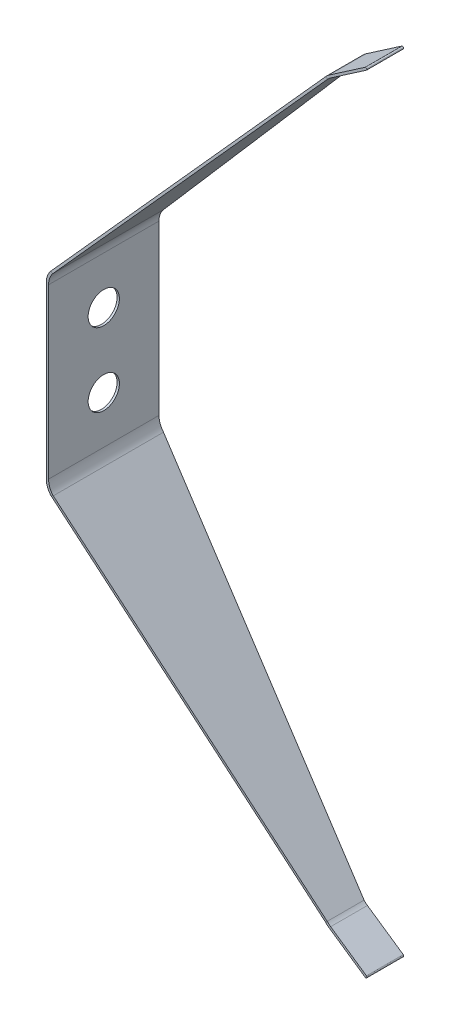
from build123d import *

# Parameters (mm, degrees)
ESTRUSIONE_ESTRUSIONE1_DEPTH      = 6
ESTRUSIONE_ESTRUSIONE1_DEPTH_BACK = 6
FORO_PER_VITE_M3_1_D              = 3.4
RACCORDO1_R                       = 2
RACCORDO2_R                       = 2
RACCORDO3_R                       = 2
RACCORDO4_R                       = 2
RACCORDO5_R                       = 2
RACCORDO6_R                       = 2
RACCORDO7_R                       = 2
RACCORDO8_R                       = 2
TAGLIO_ESTRUSIONE2_DEPTH          = 60.591921093
TAGLIO_ESTRUSIONE3_DEPTH          = 60.591921093


with BuildPart() as part:
    # Schizzo1 → Estrusione-Estrusione1 (new, two sides: drawn at the far end of the back side and taken through both)
    with BuildSketch(Plane.XY.offset(-ESTRUSIONE_ESTRUSIONE1_DEPTH_BACK)):
        with BuildLine():
            Line((0, -10), (0, 10))
            Line((0, 10), (26.541757937, 40))
            Line((26.541757937, 40), (30.66238888, 42.832031185))
            ThreePointArc((30.66238888, 42.832031185), (30.836205433, 42.799816191), (30.803990439, 42.625999637))
            Line((30.803990439, 42.625999637), (26.708656989, 39.811354938))
            Line((26.708656989, 39.811354938), (0.25, 9.905283473))
            Line((0.25, 9.905283473), (0.25, -9.905283473))
            Line((0.25, -9.905283473), (26.708656989, -39.811354938))
            Line((26.708656989, -39.811354938), (30.803990439, -42.625999637))
            ThreePointArc((30.803990439, -42.625999637), (30.836205433, -42.799816191), (30.66238888, -42.832031185))
            Line((30.66238888, -42.832031185), (26.541757937, -40))
            Line((26.541757937, -40), (0, -10))
        make_face()
    extrude(amount=ESTRUSIONE_ESTRUSIONE1_DEPTH + ESTRUSIONE_ESTRUSIONE1_DEPTH_BACK)

    # Foro per Vite M3-1 (through all)
    with Locations(Plane(origin=(0.25, 0, 0), x_dir=(0, 0, -1), z_dir=(1, 0, 0))):
        with Locations((0, 4), (0, -4)):
            Hole(FORO_PER_VITE_M3_1_D / 2)

    # Raccordo1
    raccordo1_edges = [part.edges().sort_by_distance(p)[0] for p in [
        (0, 10, 0),
    ]]
    fillet(raccordo1_edges, radius=RACCORDO1_R)

    # Raccordo2
    raccordo2_edges = [part.edges().sort_by_distance(p)[0] for p in [
        (0, -10, 0),
    ]]
    fillet(raccordo2_edges, radius=RACCORDO2_R)

    # Raccordo3
    raccordo3_edges = [part.edges().sort_by_distance(p)[0] for p in [
        (26.541757937, -40, 0),
    ]]
    fillet(raccordo3_edges, radius=RACCORDO3_R)

    # Raccordo4
    raccordo4_edges = [part.edges().sort_by_distance(p)[0] for p in [
        (26.541757937, 40, 0),
    ]]
    fillet(raccordo4_edges, radius=RACCORDO4_R)

    # Raccordo5
    raccordo5_edges = [part.edges().sort_by_distance(p)[0] for p in [
        (0.25, -9.905283473, 0),
    ]]
    fillet(raccordo5_edges, radius=RACCORDO5_R)

    # Raccordo6
    raccordo6_edges = [part.edges().sort_by_distance(p)[0] for p in [
        (0.25, 9.905283473, 0),
    ]]
    fillet(raccordo6_edges, radius=RACCORDO6_R)

    # Raccordo7
    raccordo7_edges = [part.edges().sort_by_distance(p)[0] for p in [
        (26.708656989, 39.811354938, 0),
    ]]
    fillet(raccordo7_edges, radius=RACCORDO7_R)

    # Raccordo8
    raccordo8_edges = [part.edges().sort_by_distance(p)[0] for p in [
        (26.708656989, -39.811354938, 0),
    ]]
    fillet(raccordo8_edges, radius=RACCORDO8_R)

    # Schizzo4 → Taglio-Estrusione2 (cut, through all)
    with BuildSketch(Plane(origin=(-4.962730758, 4.390653283, 0), x_dir=(0, 0, 1), z_dir=(-0.7489557207890011, 0.6626200482157386, 0))):
        Polygon((2, 47.299760633), (6, 8.247289425), (6, 59.846735232), (2, 59.846735232), align=None)
        Polygon((-2, 47.299760633), (-6, 8.247289425), (-6, 59.846735232), (-2, 59.846735232), align=None)
    extrude(amount=-TAGLIO_ESTRUSIONE2_DEPTH, mode=Mode.SUBTRACT)

    # Schizzo6 → Taglio-Estrusione3 (cut, through all)
    with BuildSketch(Plane(origin=(-4.962730758, -4.390653283, 0), x_dir=(0, 0, 1), z_dir=(-0.7489557207890011, -0.6626200482157386, 0))):
        Polygon((6, -8.247289425), (2, -47.299760633), (2, -59.491955382), (6, -59.491955382), align=None)
        Polygon((-2, -47.299760633), (-6, -8.247289425), (-6, -59.491955382), (-2, -59.491955382), align=None)
    extrude(amount=-TAGLIO_ESTRUSIONE3_DEPTH, mode=Mode.SUBTRACT)


solid = part.part
